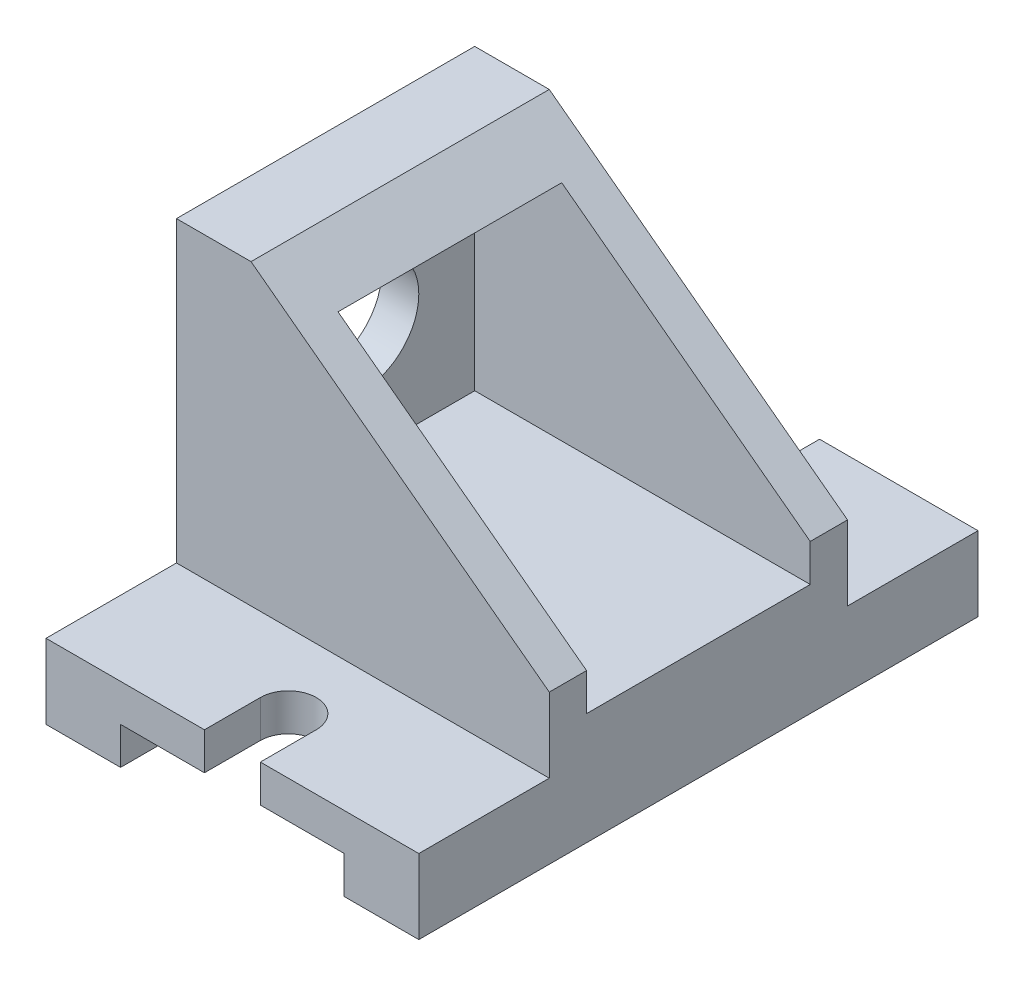
from build123d import *

# Parameters (mm, degrees)
SKETCH1_W           = 100
SKETCH1_H           = 100
BOSS_EXTRUDE2_DEPTH = 150
CUT_EXTRUDE1_DEPTH  = 80
CUT_EXTRUDE2_DEPTH  = 103
SKETCH3_W           = 60
SKETCH3_H           = 10
CUT_EXTRUDE3_DEPTH  = 178
CUT_EXTRUDE4_DEPTH  = 81
SKETCH5_W           = 60
SKETCH5_H           = 60
SKETCH5_R           = 15
CUT_EXTRUDE5_DEPTH  = 90
SKETCH6_R           = 15
CUT_EXTRUDE6_DEPTH  = 128


with BuildPart() as part:
    # Sketch1 → Boss-Extrude2 (new body)
    with BuildSketch(Plane.XY):
        with Locations((50, 50)):
            Rectangle(SKETCH1_W, SKETCH1_H)
    extrude(amount=-BOSS_EXTRUDE2_DEPTH)

    # Sketch2 → Cut-Extrude1 (cut)
    with BuildSketch(Plane(origin=(0, 100, 0), x_dir=(1, 0, 0), z_dir=(0, 1, 0))):
        with BuildLine():
            ThreePointArc((57.5, 135), (50, 127.5), (42.5, 135))
            Line((42.5, 135), (42.5, 150))
            Line((42.5, 150), (0, 150))
            Line((0, 150), (0, 115))
            Line((0, 115), (100, 115))
            Line((100, 115), (100, 150))
            Line((100, 150), (57.5, 150))
            Line((57.5, 150), (57.5, 135))
        make_face()
        with BuildLine():
            Line((100, 35), (0, 35))
            Line((0, 35), (0, 0))
            Line((0, 0), (42.5, 0))
            Line((42.5, 0), (42.5, 15))
            ThreePointArc((42.5, 15), (50, 22.5), (57.5, 15))
            Line((57.5, 15), (57.5, 0))
            Line((57.5, 0), (100, 0))
            Line((100, 0), (100, 35))
        make_face()
    extrude(amount=-CUT_EXTRUDE1_DEPTH, mode=Mode.SUBTRACT)

    # Sketch2_3 → Cut-Extrude2 (cut)
    with BuildSketch(Plane(origin=(0, 100, 0), x_dir=(1, 0, 0), z_dir=(0, 1, 0))):
        with BuildLine():
            Line((42.5, 150), (42.5, 135))
            ThreePointArc((42.5, 135), (50, 127.5), (57.5, 135))
            Line((57.5, 135), (57.5, 150))
            Line((57.5, 150), (42.5, 150))
        make_face()
        with BuildLine():
            Line((57.5, 0), (57.5, 15))
            ThreePointArc((57.5, 15), (50, 22.5), (42.5, 15))
            Line((42.5, 15), (42.5, 0))
            Line((42.5, 0), (57.5, 0))
        make_face()
    extrude(amount=-CUT_EXTRUDE2_DEPTH, mode=Mode.SUBTRACT)

    # Sketch3 → Cut-Extrude3 (cut)
    with BuildSketch(Plane.XY):
        with Locations((50, 5)):
            Rectangle(SKETCH3_W, SKETCH3_H)
    extrude(amount=-CUT_EXTRUDE3_DEPTH, mode=Mode.SUBTRACT)

    # Sketch4 → Cut-Extrude4 (cut)
    with BuildSketch(Plane.XY.offset(-35)):
        Polygon((100, 100), (20, 100), (100, 40), align=None)
    extrude(amount=-CUT_EXTRUDE4_DEPTH, mode=Mode.SUBTRACT)

    # Sketch5 → Cut-Extrude5 (cut)
    with BuildSketch(Plane(origin=(100, 0, 0), x_dir=(0, 0, -1), z_dir=(1, 0, 0))):
        with Locations((75, 60)):
            Rectangle(SKETCH5_W, SKETCH5_H)
        with Locations((75, 60)):
            Circle(SKETCH5_R, mode=Mode.SUBTRACT)
    extrude(amount=-CUT_EXTRUDE5_DEPTH, mode=Mode.SUBTRACT)

    # Sketch6 → Cut-Extrude6 (cut)
    with BuildSketch(Plane(origin=(100, 0, 0), x_dir=(0, 0, -1), z_dir=(1, 0, 0))):
        with Locations((75, 60)):
            Circle(SKETCH6_R)
    extrude(amount=-CUT_EXTRUDE6_DEPTH, mode=Mode.SUBTRACT)


solid = part.part
